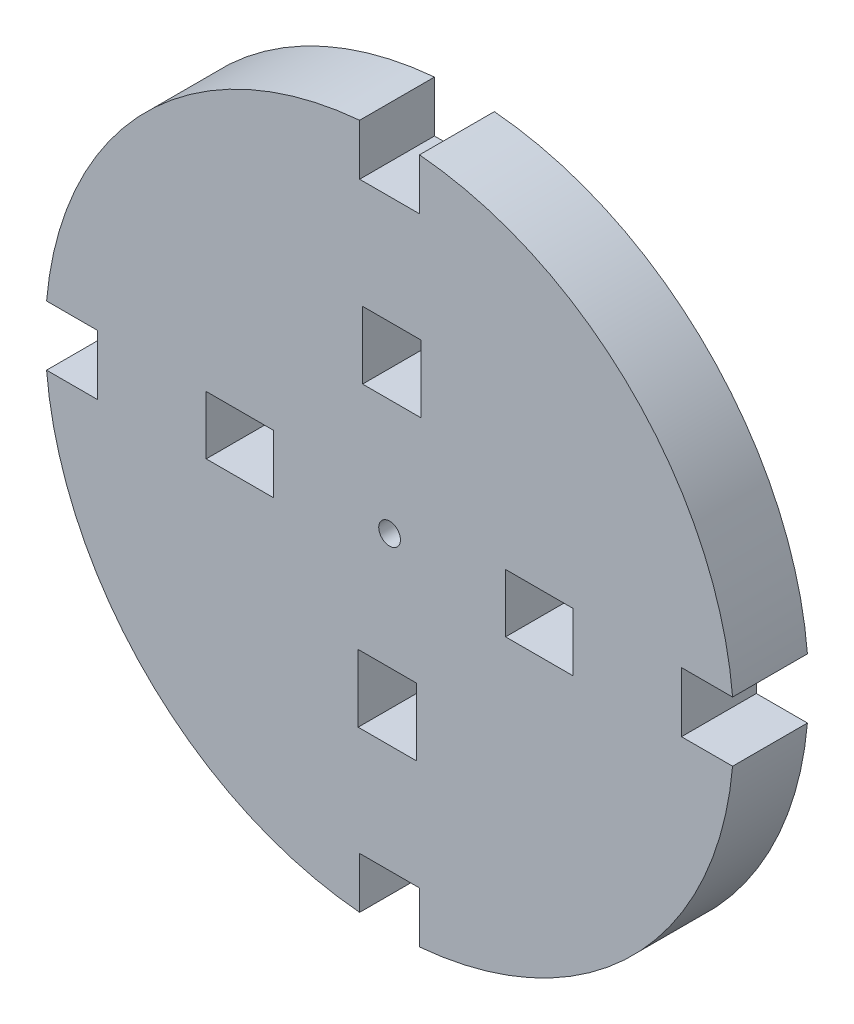
from build123d import *

# Parameters (mm, degrees)
SKETCH1_R           = 23
SKETCH1_R_2         = 0.725
BOSS_EXTRUDE1_DEPTH = 5
SKETCH2_W           = 4.5
SKETCH2_H           = 3.9
SKETCH2_W_2         = 3.9
SKETCH2_H_2         = 4.5
CUT_EXTRUDE1_DEPTH  = 6
SKETCH3_W           = 7
SKETCH3_H           = 4
SKETCH3_W_2         = 4
SKETCH3_H_2         = 7
CUT_EXTRUDE2_DEPTH  = 6


with BuildPart() as part:
    # Sketch1 → Boss-Extrude1 (new body)
    with BuildSketch(Plane.XY):
        Circle(SKETCH1_R)
        Circle(SKETCH1_R_2, mode=Mode.SUBTRACT)
    extrude(amount=BOSS_EXTRUDE1_DEPTH)

    # Sketch2 → Cut-Extrude1 (cut, through all)
    with BuildSketch(Plane(origin=(0, 0, 0), x_dir=(-1, 0, 0), z_dir=(0, 0, -1))):
        with Locations((9.999907629, 0.148804685)):
            Rectangle(SKETCH2_W, SKETCH2_H)
        with Locations((-0.147804685, 9.998907629)):
            Rectangle(SKETCH2_W_2, SKETCH2_H_2)
        with Locations((0.149804685, -9.998907629)):
            Rectangle(SKETCH2_W_2, SKETCH2_H_2)
        with Locations((-9.997907629, -0.148804685)):
            Rectangle(SKETCH2_W, SKETCH2_H)
    extrude(amount=-CUT_EXTRUDE1_DEPTH, mode=Mode.SUBTRACT)

    # Sketch3 → Cut-Extrude2 (cut, through all)
    with BuildSketch(Plane(origin=(0, 0, 0), x_dir=(-1, 0, 0), z_dir=(0, 0, -1))):
        with Locations((23, 0)):
            Rectangle(SKETCH3_W, SKETCH3_H)
        with Locations((0, 23)):
            Rectangle(SKETCH3_W_2, SKETCH3_H_2)
        with Locations((0, -23)):
            Rectangle(SKETCH3_W_2, SKETCH3_H_2)
        with Locations((-23, 0)):
            Rectangle(SKETCH3_W, SKETCH3_H)
    extrude(amount=-CUT_EXTRUDE2_DEPTH, mode=Mode.SUBTRACT)


solid = part.part
